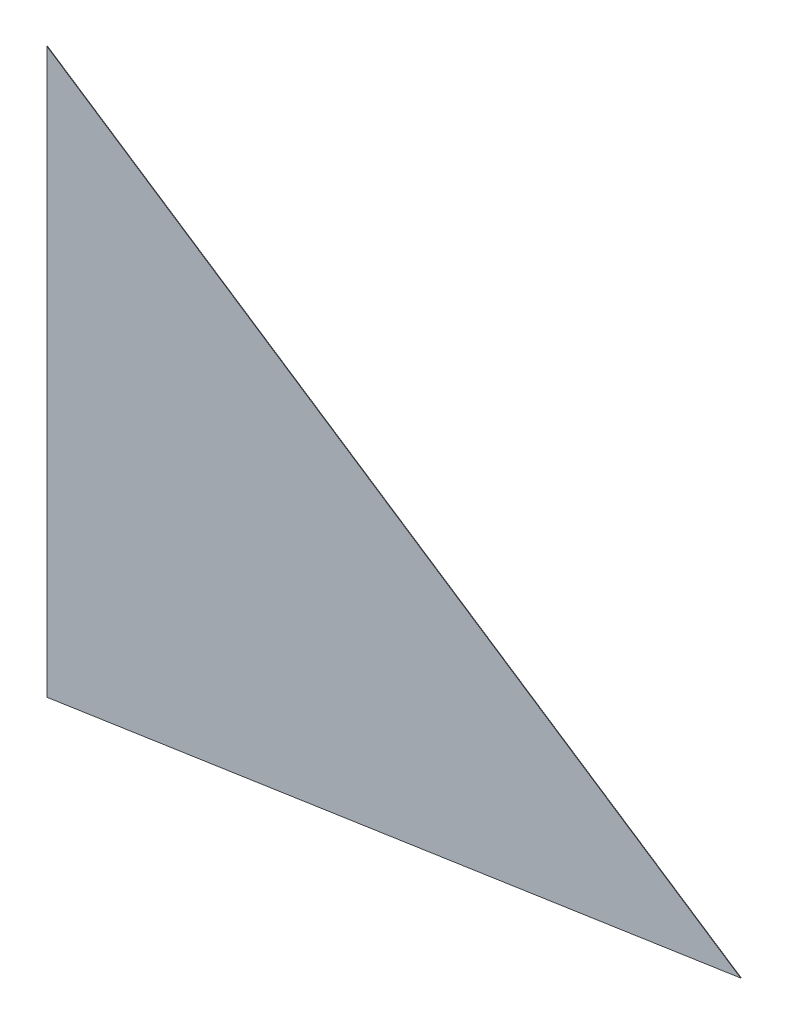
from build123d import *

# Parameters (mm, degrees)
DODANIE_WYCI_GNI_CIE1_DEPTH = 0.5


with BuildPart() as part:
    # Szkic1 → Dodanie-wyciągnięcie1 (new body)
    with BuildSketch(Plane.XY):
        Polygon((-233.875284897, -176.840766639), (-903.923901621, -277.009091385), (-903.923901621, 267.525330512), align=None)
    extrude(amount=DODANIE_WYCI_GNI_CIE1_DEPTH)


solid = part.part
